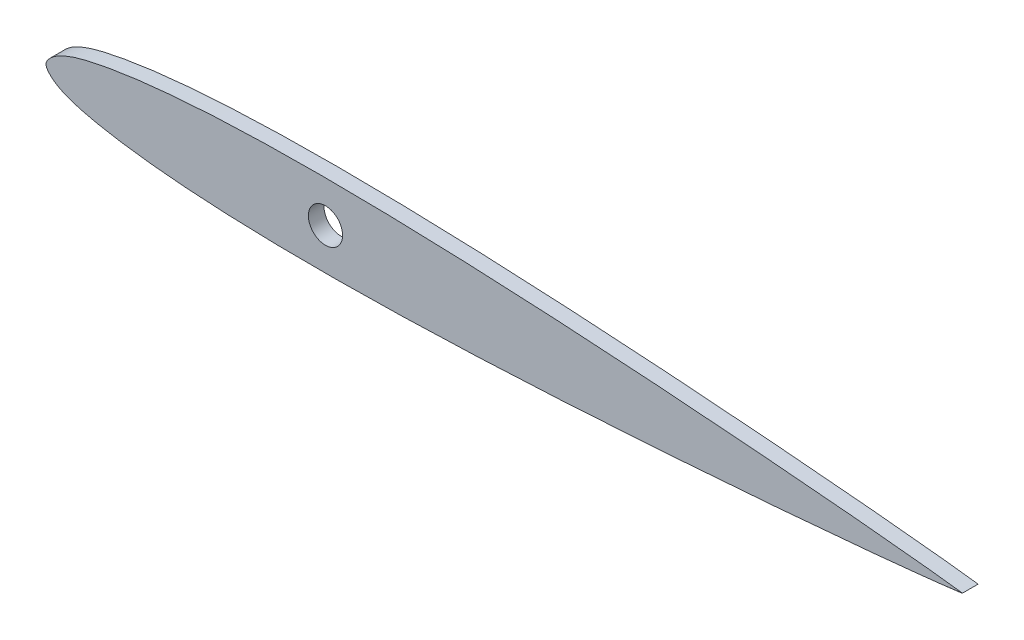
from build123d import *

# Parameters (mm, degrees)
BOSS_EXTRUDE1_DEPTH = 2.286
SKETCH6_R           = 2.499995
CUT_EXTRUDE1_DEPTH  = 3.2860001


with BuildPart() as part:
    # Sketch5 → Boss-Extrude1 (new body)
    with BuildSketch(Plane.XY):
        with BuildLine():
            add(Edge.make_bspline(
                [(133.858, 0), (133.858, 0.025572352), (132.635239995, 0.127315724), (131.381173106, 0.339626329), (128.334953604, 0.665115734), (124.592239149, 1.069140472), (119.715507644, 1.543260076), (113.989956531, 2.066482106), (107.44063652, 2.628702788), (100.204596194, 3.213470356), (92.397202136, 3.797427293), (84.154588087, 4.363270576), (75.617194084, 4.884962922), (66.93119981, 5.340411531), (58.244913897, 5.702542449), (51.072617782, 5.911739437), (45.446359676, 6.007843065), (41.353270177, 6.041949799), (37.369416299, 6.037185506), (33.511837221, 5.985902621), (29.797352234, 5.895884123), (26.2421745, 5.759936699), (22.861245753, 5.583010509), (19.66859643, 5.360981244), (16.677764128, 5.097605832), (13.902522636, 4.790578253), (11.354439687, 4.445751695), (9.043478402, 4.072015524), (6.979263272, 3.671043695), (5.168499983, 3.244225805), (3.619763578, 2.777187902), (2.336415632, 2.261279527), (1.330198654, 1.692045623), (0.606605893, 1.097639804), (0.154717172, 0.552843268), (-0.063310242, 3e-08), (0.154717172, -0.552843207), (0.606605893, -1.097639744), (1.330198653, -1.692045564), (2.336415631, -2.261279467), (3.619763576, -2.777187843), (5.168499981, -3.244225747), (6.97926327, -3.671043638), (9.0434784, -4.072015468), (11.354439685, -4.445751639), (13.902522634, -4.790578199), (16.677764125, -5.09760578), (19.668596427, -5.360981193), (22.861245751, -5.583010459), (26.242174497, -5.75993665), (29.797352231, -5.895884076), (33.511837218, -5.985902576), (37.369416296, -6.037185463), (41.353270174, -6.041949758), (45.446359674, -6.007843025), (51.07261778, -5.9117394), (58.244913895, -5.702542415), (66.931199807, -5.340411501), (75.617194082, -4.884962895), (84.154588085, -4.363270553), (92.397202135, -3.797427274), (100.204596193, -3.213470341), (107.440636519, -2.628702776), (113.98995653, -2.066482097), (119.715507643, -1.54326007), (124.592239149, -1.069140468), (128.334953604, -0.665115731), (131.381173106, -0.339626328), (132.635239995, -0.127315723), (133.858, -0.025572352), (133.858, 0)],
                knots=[0, 0, 0, 0, 0.002133427, 0.008488156, 0.018944487, 0.033319114, 0.051356294, 0.072756093, 0.097140817, 0.124097489, 0.153162557, 0.183833918, 0.215589374, 0.247878195, 0.280150868, 0.311860397, 0.327332943, 0.342462846, 0.357187102, 0.371448118, 0.385183441, 0.398331273, 0.410844637, 0.422672607, 0.433769314, 0.444090175, 0.453589412, 0.46224044, 0.470010037, 0.476870985, 0.482833353, 0.487908551, 0.492155164, 0.495592273, 0.498196359, 0.5, 0.501803641, 0.504407727, 0.507844836, 0.512091449, 0.517166647, 0.523129015, 0.529989963, 0.53775956, 0.546410588, 0.555909825, 0.566230686, 0.577327393, 0.589155363, 0.601668727, 0.614816559, 0.628551882, 0.642812898, 0.657537154, 0.672667057, 0.688139603, 0.719849132, 0.752121805, 0.784410626, 0.816166082, 0.846837443, 0.875902511, 0.902859183, 0.927243907, 0.948643706, 0.966680886, 0.981055513, 0.991511844, 0.997866573, 1, 1, 1, 1], degree=3))
        make_face()
    extrude(amount=BOSS_EXTRUDE1_DEPTH)

    # Sketch6 → Cut-Extrude1 (cut, through all)
    with BuildSketch(Plane.XY.offset(2.286)):
        with Locations((40.82669, 0)):
            Circle(SKETCH6_R)
    extrude(amount=-CUT_EXTRUDE1_DEPTH, mode=Mode.SUBTRACT)


solid = part.part
